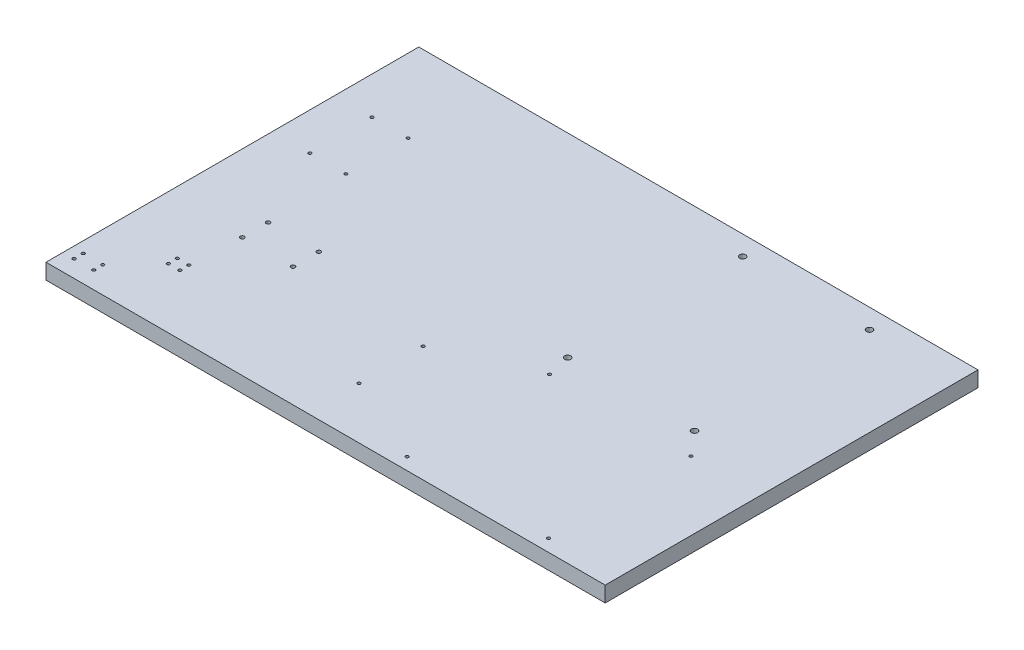
from build123d import *

# Parameters (mm, degrees)
SKETCH1_W           = 457.2
SKETCH1_H           = 304.8
BOSS_EXTRUDE1_DEPTH = 12.7
M3_TAPPED_HOLE1_D   = 2.5
M3_TAPPED_HOLE2_D   = 2.5
M4_TAPPED_HOLE1_D   = 3.3
M6_TAPPED_HOLE1_D   = 5
M3_TAPPED_HOLE3_D   = 2.5
M3_TAPPED_HOLE4_D   = 2.5


with BuildPart() as part:
    # Sketch1 → Boss-Extrude1 (new body)
    with BuildSketch(Plane(origin=(0, 0, 0), x_dir=(1, 0, 0), z_dir=(0, 1, 0))):
        with Locations((228.6, 152.4)):
            Rectangle(SKETCH1_W, SKETCH1_H)
    extrude(amount=BOSS_EXTRUDE1_DEPTH)

    # M3 Tapped Hole1 (through all)
    with Locations(Plane(origin=(0, 12.7, 0), x_dir=(1, 0, 0), z_dir=(0, 1, 0))):
        with Locations((9, 21.4), (25, 21.4), (25, 14), (9, 14), (51, 56.4), (60.4, 56.4), (60.4, 49), (51, 49)):
            Hole(M3_TAPPED_HOLE1_D / 2)

    # M3 Tapped Hole2 (through all)
    with Locations(Plane(origin=(0, 12.7, 0), x_dir=(1, 0, 0), z_dir=(0, 1, 0))):
        with Locations((60.1249844, 235.924), (60.1249844, 185.124), (30.6249948, 185.124), (30.6249948, 235.924)):
            Hole(M3_TAPPED_HOLE2_D / 2)

    # M4 Tapped Hole1 (through all)
    with Locations(Plane(origin=(0, 12.7, 0), x_dir=(1, 0, 0), z_dir=(0, 1, 0))):
        with Locations((62.65, 97.849261314), (62.65, 118.949261314), (104.15, 118.949261314), (104.15, 97.849261314)):
            Hole(M4_TAPPED_HOLE1_D / 2)

    # M6 Tapped Hole1 (through all)
    with Locations(Plane(origin=(0, 12.7, 0), x_dir=(1, 0, 0), z_dir=(0, 1, 0))):
        with Locations((384.5, 288.8), (280.778201797, 288.8), (280.778201797, 145.71), (384.5, 145.71)):
            Hole(M6_TAPPED_HOLE1_D / 2)

    # M3 Tapped Hole3 (through all)
    with Locations(Plane(origin=(0, 12.7, 0), x_dir=(1, 0, 0), z_dir=(0, 1, 0))):
        with Locations((213.72, 94.65), (213.72, 42.15)):
            Hole(M3_TAPPED_HOLE3_D / 2)

    # M3 Tapped Hole4 (through all)
    with Locations(Plane(origin=(0, 12.7, 0), x_dir=(1, 0, 0), z_dir=(0, 1, 0))):
        with Locations((400.9, 10), (285.3, 10), (285.3, 126.425), (400.9, 126.425)):
            Hole(M3_TAPPED_HOLE4_D / 2)


solid = part.part
